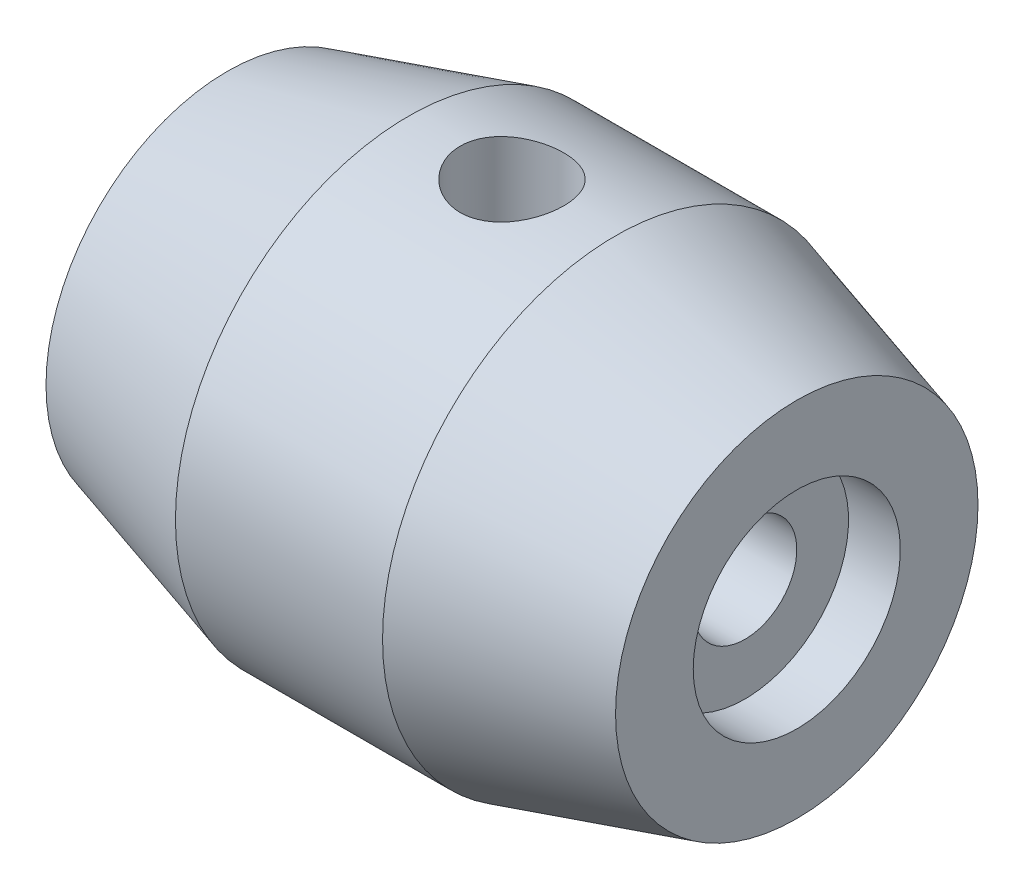
from build123d import *

# Parameters (mm, degrees)
SKETCH3_R               = 0.5
CUT_EXTRUDE2_DEPTH      = 1.25
CUT_EXTRUDE2_DEPTH_BACK = 5.25


with BuildPart() as part:
    # Sketch1 → Revolve1 (revolve)
    with BuildSketch(Plane(origin=(0, 0, 0), x_dir=(1, 0, 0), z_dir=(0, 1, 0))):
        Polygon((0, 0), (4.5, 0), (4.5, 0.5), (5, 0.5), (5, 1.25), (3.25, 1.75), (1.25, 1.75), (-0.5, 1.25), (-0.5, 0.5), (0, 0.5), align=None)
    revolve(axis=Axis((0, 0, 0.5), (1, 0, 0)))

    # Sketch3 → Cut-Extrude2 (cut, two sides)
    with BuildSketch(Plane(origin=(0, 2, 0), x_dir=(1, 0, 0), z_dir=(0, 1, 0))) as cut_extrude2_sk:
        with Locations((2.25, -0.5)):
            Circle(SKETCH3_R)
    extrude(amount=CUT_EXTRUDE2_DEPTH, mode=Mode.SUBTRACT)
    extrude(cut_extrude2_sk.sketch, amount=-CUT_EXTRUDE2_DEPTH_BACK, mode=Mode.SUBTRACT)


solid = part.part
